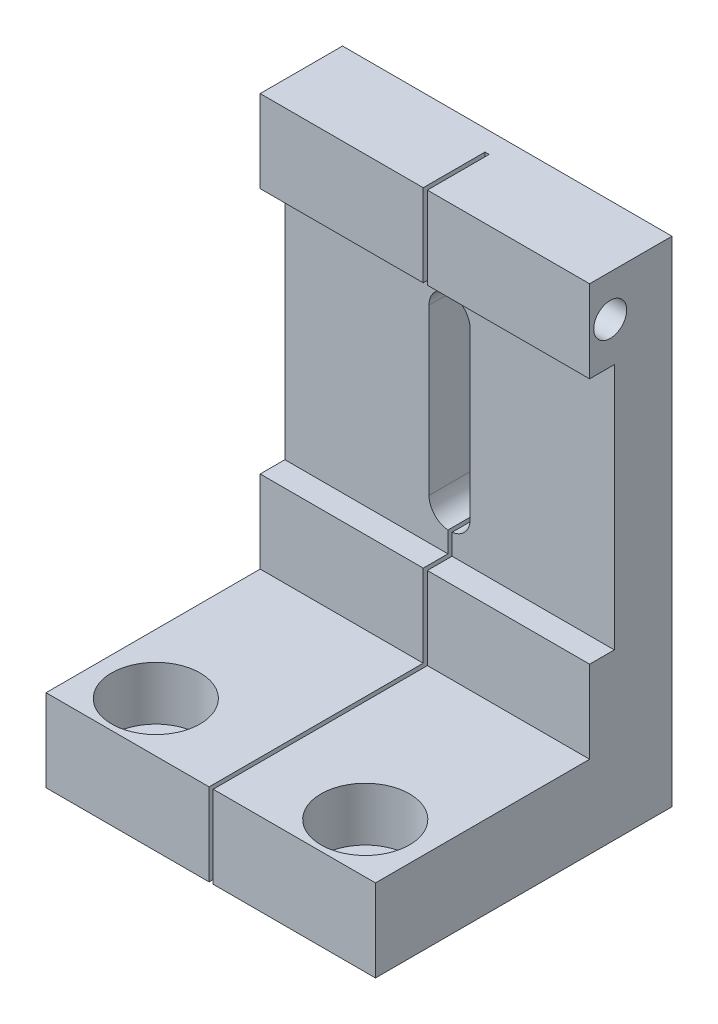
from build123d import *

# Parameters (mm, degrees)
SKETCH1_W           = 40
SKETCH1_H           = 60
BOSS_EXTRUDE1_DEPTH = 10
CUT_EXTRUDE1_DEPTH  = 11
SKETCH5_W           = 3
SKETCH5_H           = 30
CUT_EXTRUDE4_DEPTH  = 41
SKETCH6_W           = 40
SKETCH6_H           = 10
BOSS_EXTRUDE2_DEPTH = 26
SKETCH8_W           = 0.5
SKETCH8_H           = 33.5
CUT_EXTRUDE7_DEPTH  = 60
SKETCH10_R          = 2
CUT_EXTRUDE10_DEPTH = 30
SKETCH12_R          = 3.4
SKETCH12_R_2        = 2.49
CUT_EXTRUDE13_DEPTH = 10
SKETCH14_R          = 5.375
CUT_EXTRUDE14_DEPTH = 6.5


with BuildPart() as part:
    # Sketch1 → Boss-Extrude1 (new body)
    with BuildSketch(Plane.XY):
        with Locations((-20, -30)):
            Rectangle(SKETCH1_W, SKETCH1_H)
    extrude(amount=BOSS_EXTRUDE1_DEPTH)

    # Sketch2 → Cut-Extrude1 (cut, through all)
    with BuildSketch(Plane.XY.offset(10)):
        with BuildLine():
            Line((-17.5, -15), (-17.5, -35))
            ThreePointArc((-17.5, -35), (-20, -37.5), (-22.5, -35))
            Line((-22.5, -35), (-22.5, -15))
            ThreePointArc((-22.5, -15), (-20, -12.5), (-17.5, -15))
        make_face()
    extrude(amount=-CUT_EXTRUDE1_DEPTH, mode=Mode.SUBTRACT)

    # Sketch5 → Cut-Extrude4 (cut, through all)
    with BuildSketch(Plane(origin=(0, 0, 0), x_dir=(0, 0, -1), z_dir=(1, 0, 0))):
        with Locations((-8.5, -25)):
            Rectangle(SKETCH5_W, SKETCH5_H)
    extrude(amount=-CUT_EXTRUDE4_DEPTH, mode=Mode.SUBTRACT)

    # Sketch6 → Boss-Extrude2 (add)
    with BuildSketch(Plane.XY.offset(10)):
        with Locations((-20, -55)):
            Rectangle(SKETCH6_W, SKETCH6_H)
    extrude(amount=BOSS_EXTRUDE2_DEPTH)

    # Sketch8 → Cut-Extrude7 (cut)
    with BuildSketch(Plane(origin=(0, 0, 0), x_dir=(1, 0, 0), z_dir=(0, 1, 0))):
        with Locations((-19.95, -19.25)):
            Rectangle(SKETCH8_W, SKETCH8_H)
    extrude(amount=-CUT_EXTRUDE7_DEPTH, mode=Mode.SUBTRACT)

    # Sketch10 → Cut-Extrude10 (cut)
    with BuildSketch(Plane(origin=(0, 0, 0), x_dir=(0, 0, -1), z_dir=(1, 0, 0))):
        with Locations((-7.5, -5)):
            Circle(SKETCH10_R)
    extrude(amount=-CUT_EXTRUDE10_DEPTH, mode=Mode.SUBTRACT)

    # Sketch12 → Cut-Extrude13 (cut)
    with BuildSketch(Plane.XZ.offset(60)):
        with Locations((-7.3, 29.94)):
            Circle(SKETCH12_R)
        with Locations((-32.73, 29.94)):
            Circle(SKETCH12_R)
        with Locations((-32.73, 4.51)):
            Circle(SKETCH12_R_2)
        with Locations((-7.3, 4.51)):
            Circle(SKETCH12_R_2)
    extrude(amount=-CUT_EXTRUDE13_DEPTH, mode=Mode.SUBTRACT)

    # Sketch14 → Cut-Extrude14 (cut)
    with BuildSketch(Plane(origin=(0, -50, 0), x_dir=(1, 0, 0), z_dir=(0, 1, 0))):
        with Locations((-32.73, -29.94)):
            Circle(SKETCH14_R)
        with Locations((-7.3, -29.94)):
            Circle(SKETCH14_R)
    extrude(amount=-CUT_EXTRUDE14_DEPTH, mode=Mode.SUBTRACT)


solid = part.part
